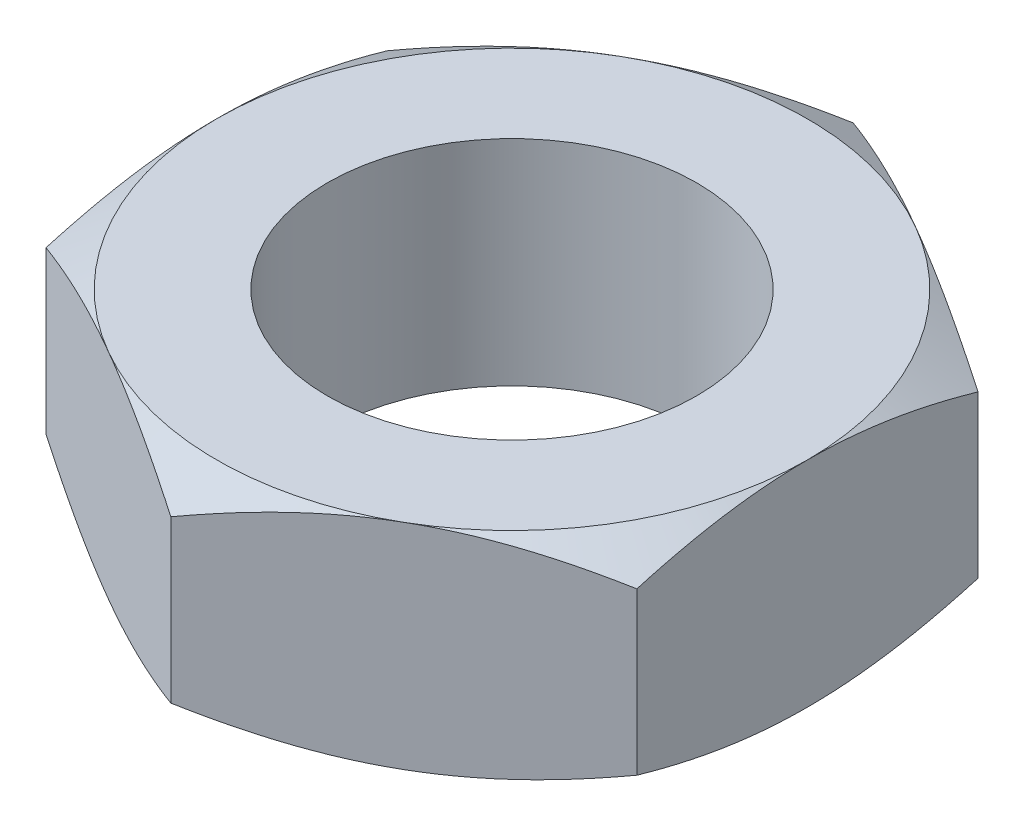
from build123d import *

# Parameters (mm, degrees)
SKETCH1_R               = 2.5
BOSS_EXTRUDE1_DEPTH     = 1.45
SKETCH5_OUTSIDE_W       = 39.406
SKETCH5_OUTSIDE_H       = 40.644
SKETCH5_OUTSIDE_R       = 4
CUT_EXTRUDE2_DEPTH      = 7.763381797
CUT_EXTRUDE2_DRAFT      = -60
MIRROR1_COPY_1_SKETCH_W = 39.406
MIRROR1_COPY_1_SKETCH_H = 40.644
MIRROR1_COPY_1_SKETCH_R = 4
MIRROR1_COPY_1_DEPTH    = 7.763381797
MIRROR1_COPY_1_DRAFT    = -60


with BuildPart() as part:
    # Sketch1 → Boss-Extrude1 (new, symmetric)
    with BuildSketch(Plane(origin=(0, 0, 0), x_dir=(1, 0, 0), z_dir=(0, 1, 0))):
        Polygon((-4, 2.309401077), (-4, -2.309401077), (0, -4.618802154), (4, -2.309401077), (4, 2.309401077), (0, 4.618802154), align=None)
        Circle(SKETCH1_R, mode=Mode.SUBTRACT)
    extrude(amount=BOSS_EXTRUDE1_DEPTH, both=True)


with BuildPart() as cut_extrude2_tool:
    # Sketch5 outside → Cut-Extrude2 (with draft: the straight prism first)
    with BuildSketch(Plane(origin=(0, 1.45, 0), x_dir=(1, 0, 0), z_dir=(0, 1, 0))):
        Rectangle(SKETCH5_OUTSIDE_W, SKETCH5_OUTSIDE_H)
        Circle(SKETCH5_OUTSIDE_R, mode=Mode.SUBTRACT)
    extrude(amount=-CUT_EXTRUDE2_DEPTH)
    # Cut-Extrude2: the draft: its side faces are tilted about the plane it starts from
    cut_extrude2_sides = [cut_extrude2_tool.faces().sort_by_distance(p)[0] for p in [
        (0, -2.431690899, 20.322),
        (19.703, -2.431690899, 0),
        (0, -2.431690899, -20.322),
        (-19.703, -2.431690899, 0),
        (-4, -2.431690899, 0),
    ]]
    draft(cut_extrude2_sides, Plane(origin=(0, 1.45, 0), x_dir=(1, 0, 0), z_dir=(0, 1, 0)), CUT_EXTRUDE2_DRAFT)


with BuildPart() as part_1:
    add(part.part)

    # Cut-Extrude2: cut by cut_extrude2_tool
    add(cut_extrude2_tool.part, mode=Mode.SUBTRACT)


with BuildPart() as mirror1_copy_1_tool:
    # Mirror1 copy 1 sketch → Mirror1 copy 1 (with draft: the straight prism first)
    with BuildSketch(Plane.XZ.offset(1.45)):
        Rectangle(MIRROR1_COPY_1_SKETCH_W, MIRROR1_COPY_1_SKETCH_H)
        Circle(MIRROR1_COPY_1_SKETCH_R, mode=Mode.SUBTRACT)
    extrude(amount=-MIRROR1_COPY_1_DEPTH)
    # Mirror1 copy 1: the draft: its side faces are tilted about the plane it starts from
    mirror1_copy_1_sides = [mirror1_copy_1_tool.faces().sort_by_distance(p)[0] for p in [
        (0, 2.431690899, 20.322),
        (19.703, 2.431690899, 0),
        (0, 2.431690899, -20.322),
        (-19.703, 2.431690899, 0),
        (-4, 2.431690899, 0),
    ]]
    draft(mirror1_copy_1_sides, Plane.XZ.offset(1.45), MIRROR1_COPY_1_DRAFT)


with BuildPart() as part_2:
    add(part_1.part)

    # Mirror1 copy 1: cut by mirror1_copy_1_tool
    add(mirror1_copy_1_tool.part, mode=Mode.SUBTRACT)


solid = part_2.part
